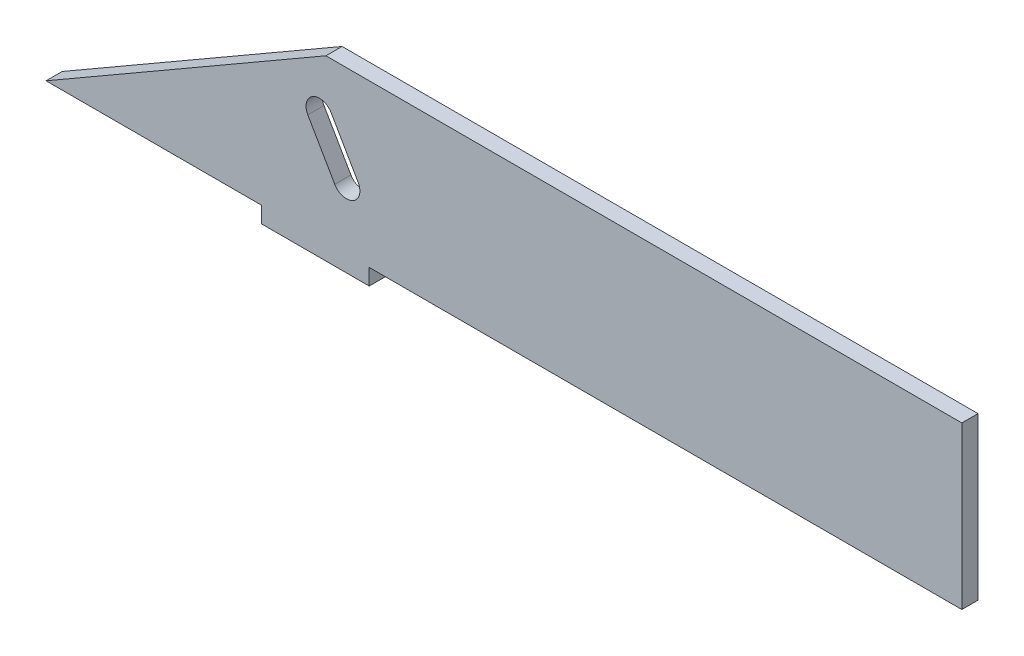
from build123d import *

# Parameters (mm, degrees)
BOSS_EXTRUDE1_DEPTH     = 3
CUT_EXTRUDE3_DEPTH      = 1
CUT_EXTRUDE3_DEPTH_BACK = 3
CUT_EXTRUDE4_DEPTH      = 4
SKETCH6_W               = 3
SKETCH6_H               = 30
BOSS_EXTRUDE2_DEPTH     = 70


with BuildPart() as part:
    # Sketch1 → Boss-Extrude1 (new body)
    with BuildSketch(Plane.XY):
        Polygon((-10, -15), (-10, -18), (10, -18), (10, -15), (50, -15), (50, 15), (-50, 15), (-50, -15), align=None)
    extrude(amount=BOSS_EXTRUDE1_DEPTH)

    # Sketch4 → Cut-Extrude3 (cut, two sides)
    with BuildSketch(Plane.XY.offset(3)) as cut_extrude3_sk:
        Polygon((-50, -14.220304878), (-50, -15), (1.961524227, 15), (-50, 15), align=None)
    extrude(amount=CUT_EXTRUDE3_DEPTH, mode=Mode.SUBTRACT)
    extrude(cut_extrude3_sk.sketch, amount=-CUT_EXTRUDE3_DEPTH_BACK, mode=Mode.SUBTRACT)

    # Sketch5 → Cut-Extrude4 (cut)
    with BuildSketch(Plane.XY.offset(3)):
        with BuildLine():
            Line((7.930435314, -2.338457268), (2.930435314, 6.32179677))
            ThreePointArc((2.930435314, 6.32179677), (-0.484628196, 7.236860279), (-1.399691705, 3.82179677))
            Line((-1.399691705, 3.82179677), (3.600308295, -4.838457268))
            ThreePointArc((3.600308295, -4.838457268), (7.015371804, -5.753520778), (7.930435314, -2.338457268))
        make_face()
    extrude(amount=-CUT_EXTRUDE4_DEPTH, mode=Mode.SUBTRACT)

    # Sketch6 → Boss-Extrude2 (add)
    with BuildSketch(Plane(origin=(50, 0, 0), x_dir=(0, 0, -1), z_dir=(1, 0, 0))):
        with Locations((-1.5, 0)):
            Rectangle(SKETCH6_W, SKETCH6_H)
    extrude(amount=BOSS_EXTRUDE2_DEPTH)


solid = part.part
